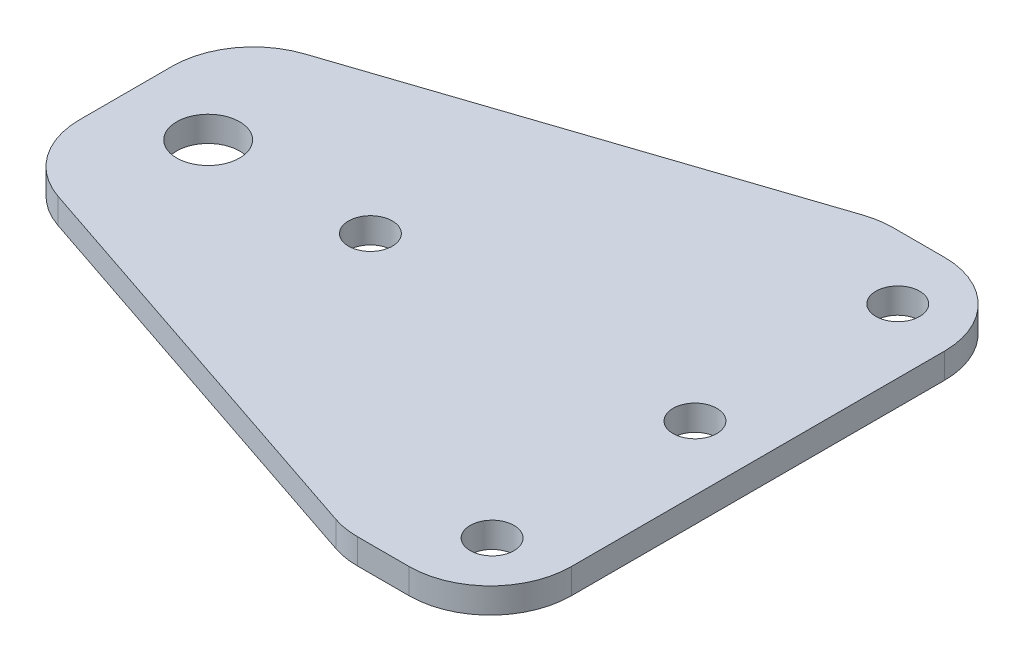
from build123d import *

# Parameters (mm, degrees)
SKETCH1_R           = 2.7
SKETCH1_R_2         = 3.875
BOSS_EXTRUDE1_DEPTH = 3.125
FILLET1_R           = 10


with BuildPart() as part:
    # Sketch1 → Boss-Extrude1 (new body)
    with BuildSketch(Plane(origin=(0, 0, 0), x_dir=(1, 0, 0), z_dir=(0, 1, 0))):
        Polygon((0, 25.810224973), (0, 0), (60, -20.189775027), (78, -20.189775027), (78, 45.810224973), (60, 45.810224973), align=None)
        with Locations((70.074055608, -12.033915485)):
            Circle(SKETCH1_R, mode=Mode.SUBTRACT)
        with Locations((10.074055608, 12.966084515)):
            Circle(SKETCH1_R_2, mode=Mode.SUBTRACT)
        with Locations((70.074055608, 37.966084515)):
            Circle(SKETCH1_R, mode=Mode.SUBTRACT)
        with Locations((70.074055608, 12.966084515)):
            Circle(SKETCH1_R, mode=Mode.SUBTRACT)
        with Locations((30.074055608, 12.966084515)):
            Circle(SKETCH1_R, mode=Mode.SUBTRACT)
    extrude(amount=BOSS_EXTRUDE1_DEPTH)

    # Fillet1
    fillet1_edges = [part.edges().sort_by_distance(p)[0] for p in [
        (60, 1.5625, -45.810224973),
        (78, 1.5625, -45.810224973),
        (78, 1.5625, 20.189775027),
        (60, 1.5625, 20.189775027),
        (0, 1.5625, 0),
        (0, 1.5625, -25.810224973),
    ]]
    fillet(fillet1_edges, radius=FILLET1_R)


solid = part.part
